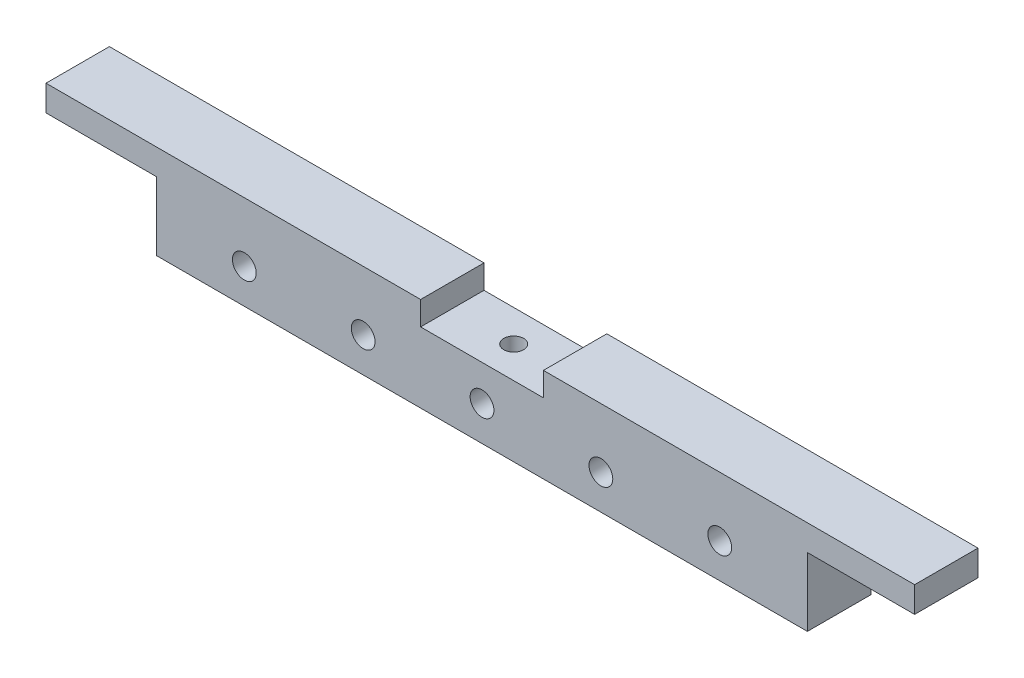
from build123d import *

# Parameters (mm, degrees)
CROQUIS1_R              = 6
SALIENTE_EXTRUIR1_DEPTH = 32
CROQUIS2_R              = 5
CORTAR_EXTRUIR1_DEPTH   = 10


with BuildPart() as part:
    # Croquis1 → Saliente-Extruir1 (new body)
    with BuildSketch(Plane.XY):
        Polygon((-197.653640257, 0), (-8.534796574, 0), (-8.534796574, -12), (53.465203426, -12), (53.465203426, 0), (240.846359743, 0), (240.846359743, -13), (186.715203426, -13), (186.715203426, -47.5), (-141.784796574, -47.5), (-141.784796574, -13), (-197.653640257, -13), align=None)
        with Locations((22.465203426, -30)):
            Circle(CROQUIS1_R, mode=Mode.SUBTRACT)
        with Locations((82.465203426, -30)):
            Circle(CROQUIS1_R, mode=Mode.SUBTRACT)
        with Locations((142.465203426, -30)):
            Circle(CROQUIS1_R, mode=Mode.SUBTRACT)
        with Locations((-37.534796574, -30)):
            Circle(CROQUIS1_R, mode=Mode.SUBTRACT)
        with Locations((-97.534796574, -30)):
            Circle(CROQUIS1_R, mode=Mode.SUBTRACT)
    extrude(amount=SALIENTE_EXTRUIR1_DEPTH)

    # Croquis2 → Cortar-Extruir1 (cut)
    with BuildSketch(Plane(origin=(0, -12, 0), x_dir=(1, 0, 0), z_dir=(0, 1, 0))):
        with Locations((22.465203426, -16)):
            Circle(CROQUIS2_R)
    extrude(amount=-CORTAR_EXTRUIR1_DEPTH, mode=Mode.SUBTRACT)


solid = part.part
